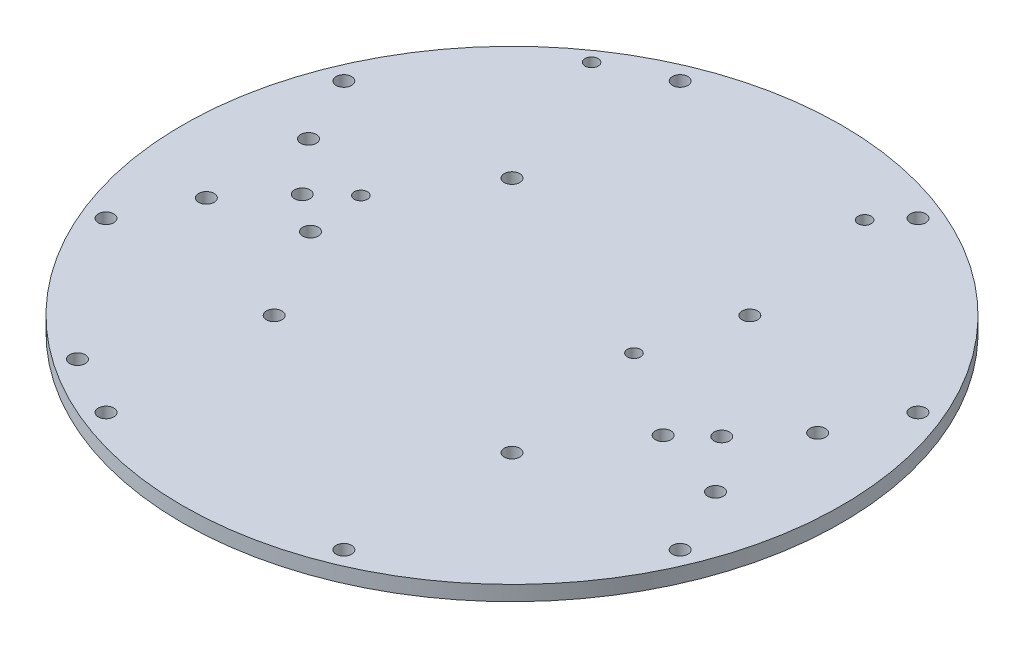
from build123d import *

# Parameters (mm, degrees)
BASE_W_MOTOR_MOUNTS_R     = 70
BASE_W_MOTOR_MOUNTS_R_2   = 1.651
BOSS_EXTRUDE1_DEPTH       = 3.175
STANDOFFS_TOP_BOTTOM_R    = 1.65
CUT_EXTRUDE2_DEPTH        = 3.175
PI_AND_MEGA_STANDOFFS_R   = 1.4
PI_AND_MEGA_STANDOFFS_R_2 = 1.65
CUT_EXTRUDE3_DEPTH        = 3.175


with BuildPart() as part:
    # Base w/ Motor Mounts → Boss-Extrude1 (new body)
    with BuildSketch(Plane(origin=(0, 0, 0), x_dir=(1, 0, 0), z_dir=(0, 1, 0))):
        Circle(BASE_W_MOTOR_MOUNTS_R)
        with Locations((44.55, 0)):
            Circle(BASE_W_MOTOR_MOUNTS_R_2, mode=Mode.SUBTRACT)
        with Locations((54.075, 10.85)):
            Circle(BASE_W_MOTOR_MOUNTS_R_2, mode=Mode.SUBTRACT)
        with Locations((54.075, -10.85)):
            Circle(BASE_W_MOTOR_MOUNTS_R_2, mode=Mode.SUBTRACT)
        with Locations((-54.075, -10.85)):
            Circle(BASE_W_MOTOR_MOUNTS_R_2, mode=Mode.SUBTRACT)
        with Locations((-54.075, 10.85)):
            Circle(BASE_W_MOTOR_MOUNTS_R_2, mode=Mode.SUBTRACT)
        with Locations((-44.55, 0)):
            Circle(BASE_W_MOTOR_MOUNTS_R_2, mode=Mode.SUBTRACT)
    extrude(amount=BOSS_EXTRUDE1_DEPTH)

    # Standoffs (top / bottom) → Cut-Extrude2 (cut)
    with BuildSketch(Plane(origin=(0, 0, 0), x_dir=(1, 0, 0), z_dir=(0, 1, 0))):
        with Locations((25.257106536, 60.976049146)):
            Circle(STANDOFFS_TOP_BOTTOM_R)
        with Locations((60.976049146, 25.257106536)):
            Circle(STANDOFFS_TOP_BOTTOM_R)
        with Locations((25.257106536, 25.257106536)):
            Circle(STANDOFFS_TOP_BOTTOM_R)
        with Locations((25.257106536, -25.257106536)):
            Circle(STANDOFFS_TOP_BOTTOM_R)
        with Locations((60.976049146, -25.257106536)):
            Circle(STANDOFFS_TOP_BOTTOM_R)
        with Locations((25.257106536, -60.976049146)):
            Circle(STANDOFFS_TOP_BOTTOM_R)
        with Locations((-25.257106536, -60.976049146)):
            Circle(STANDOFFS_TOP_BOTTOM_R)
        with Locations((-60.976049146, -25.257106536)):
            Circle(STANDOFFS_TOP_BOTTOM_R)
        with Locations((-25.257106536, -25.257106536)):
            Circle(STANDOFFS_TOP_BOTTOM_R)
        with Locations((-25.257106536, 25.257106536)):
            Circle(STANDOFFS_TOP_BOTTOM_R)
        with Locations((-60.976049146, 25.257106536)):
            Circle(STANDOFFS_TOP_BOTTOM_R)
        with Locations((-25.257106536, 60.976049146)):
            Circle(STANDOFFS_TOP_BOTTOM_R)
    extrude(amount=CUT_EXTRUDE2_DEPTH, mode=Mode.SUBTRACT)

    # Pi and Mega Standoffs → Cut-Extrude3 (cut)
    with BuildSketch(Plane(origin=(0, 0, 0), x_dir=(1, 0, 0), z_dir=(0, 1, 0))):
        with Locations((-38.1, 55)):
            Circle(PI_AND_MEGA_STANDOFFS_R)
        with Locations((19.9, 55)):
            Circle(PI_AND_MEGA_STANDOFFS_R)
        with Locations((19.9, 6)):
            Circle(PI_AND_MEGA_STANDOFFS_R)
        with Locations((-38.1, 6)):
            Circle(PI_AND_MEGA_STANDOFFS_R)
        with Locations((-38.1, -54.2)):
            Circle(PI_AND_MEGA_STANDOFFS_R_2)
        with Locations((-36.8, -6)):
            Circle(PI_AND_MEGA_STANDOFFS_R_2)
        with Locations((38.1, -6)):
            Circle(PI_AND_MEGA_STANDOFFS_R_2)
    extrude(amount=CUT_EXTRUDE3_DEPTH, mode=Mode.SUBTRACT)


solid = part.part
